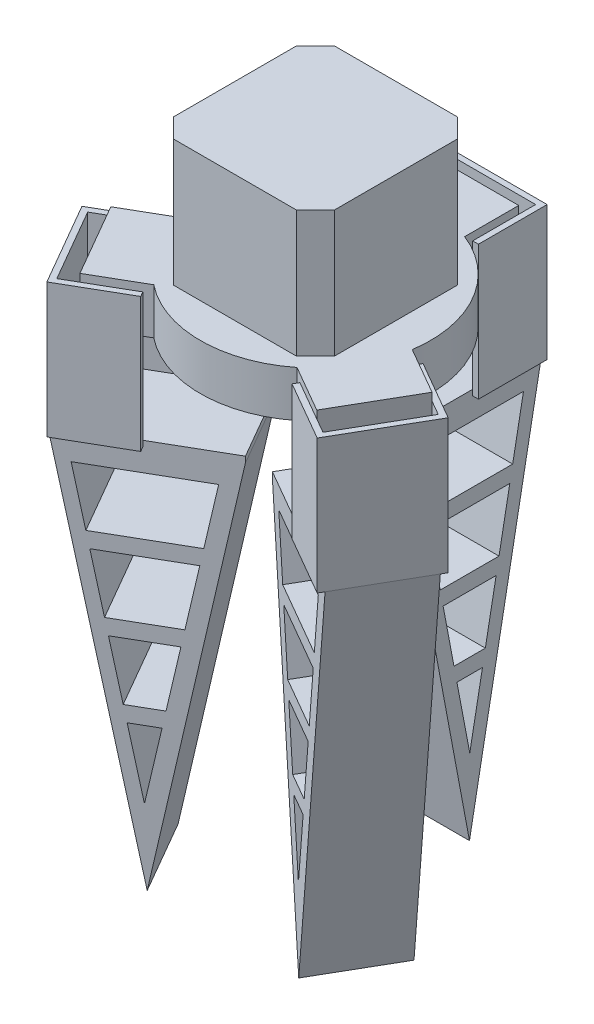
from build123d import *

# Parameters (mm, degrees)
SKETCH_1_W               = 42
SKETCH_1_H               = 42
EXTRUDE_1_DEPTH          = 33
CHAMFER_1_SIZE           = 5
EXTRUDE_2_DEPTH          = 12
EXTRUDE_START            = -10
EXTRUDE_3_DEPTH          = 35
SKETCH_5_W               = 22
SKETCH_5_H               = 36
EXTRUDE_4_DEPTH          = 1.5
EXTRUDE_5_DEPTH          = 22
PATTERN_CIRCULAR_1_COUNT = 3
CUT_EXTRUDE_1_DEPTH      = 65.991772006
CUT_EXTRUDE_2_DEPTH      = 59.741772006
CUT_EXTRUDE_3_DEPTH      = 65.991772006


with BuildPart() as part:
    # Sketch 1 → Extrude 1 (new body)
    with BuildSketch(Plane(origin=(0, 0, 0), x_dir=(1, 0, 0), z_dir=(0, 1, 0))):
        Rectangle(SKETCH_1_W, SKETCH_1_H)
    extrude(amount=EXTRUDE_1_DEPTH)

    # Chamfer 1
    chamfer_1_edges = [part.edges().sort_by_distance(p)[0] for p in [
        (21, 16.5, 21),
        (-21, 16.5, 21),
        (-21, 16.5, -21),
        (21, 16.5, -21),
    ]]
    chamfer(chamfer_1_edges, length=CHAMFER_1_SIZE)

    # Sketch 3 → Extrude 2 (add)
    with BuildSketch(Plane(origin=(0, 0, 0), x_dir=(1, 0, 0), z_dir=(0, 1, 0))):
        with BuildLine():
            Line((-11, 27.910571474), (-11, 42))
            Line((-11, 42), (11, 42))
            Line((11, 42), (11, 27.910571474))
            ThreePointArc((11, 27.910571474), (25.980762114, 15), (29.671263931, -4.429006295))
            Line((29.671263931, -4.429006295), (41.873066959, -11.473720558))
            Line((41.873066959, -11.473720558), (30.873066959, -30.526279442))
            Line((30.873066959, -30.526279442), (18.671263931, -23.481565179))
            ThreePointArc((18.671263931, -23.481565179), (0, -30), (-18.671263931, -23.481565179))
            Line((-18.671263931, -23.481565179), (-30.873066959, -30.526279442))
            Line((-30.873066959, -30.526279442), (-41.873066959, -11.473720558))
            Line((-41.873066959, -11.473720558), (-29.671263931, -4.429006295))
            ThreePointArc((-29.671263931, -4.429006295), (-25.980762114, 15), (-11, 27.910571474))
        make_face()
    extrude(amount=-EXTRUDE_2_DEPTH)

    # Sketch 4 → Extrude 3 (add)
    with BuildSketch(Plane(origin=(0, -12, 0), x_dir=(-1, 0, 0), z_dir=(0, -1, 0)).offset(EXTRUDE_START)):
        Polygon((-11, 30), (-11, 46.410571474), (11, 46.410571474), (11, 30), (12.5, 30), (12.5, 47.910571474), (-12.5, 47.910571474), (-12.5, 30), align=None)
    extrude_3 = extrude(amount=EXTRUDE_3_DEPTH)

    # Sketch 5 → Extrude 4 (add)
    with BuildSketch(Plane(origin=(0, -37, 0), x_dir=(-1, 0, 0), z_dir=(0, -1, 0))):
        with Locations((0, 28.410571474)):
            Rectangle(SKETCH_5_W, SKETCH_5_H)
    extrude_4 = extrude(amount=-EXTRUDE_4_DEPTH)

    # Sketch 6 → Extrude 5 (add)
    with BuildSketch(Plane(origin=(11, 0, 0), x_dir=(0, 0, -1), z_dir=(1, 0, 0))):
        Polygon((10.410571474, -37), (47.910571474, -37), (29.160571474, -137), align=None)
    extrude_5 = extrude(amount=-EXTRUDE_5_DEPTH)

    # Pattern Circular 1: Extrude 3, Extrude 4, Extrude 5 ×3 about axis
    pattern_circular_1_axis = Axis((0, 0, 0), (0, 1, 0))
    for i in range(1, PATTERN_CIRCULAR_1_COUNT):
        add(extrude_3.rotate(pattern_circular_1_axis, i * 360 / PATTERN_CIRCULAR_1_COUNT))
        add(extrude_4.rotate(pattern_circular_1_axis, i * 360 / PATTERN_CIRCULAR_1_COUNT))
        add(extrude_5.rotate(pattern_circular_1_axis, i * 360 / PATTERN_CIRCULAR_1_COUNT))

    # Sketch 7 → Cut-Extrude 1 (cut, through all)
    with BuildSketch(Plane(origin=(5.5, 0, -9.526279442), x_dir=(-0.866025404, 0, -0.5), z_dir=(0.5, 0, -0.866025404))):
        Polygon((-40.245205142, -56), (-17.739434055, -56), (-14.926151928, -41), (-26.07846167, -41), (-43.090866325, -41), align=None)
        Polygon((-39.48636216, -60), (-18.489642622, -60), (-21.302924749, -75), (-36.640700976, -75), align=None)
        Polygon((-35.881857994, -79), (-22.053133316, -79), (-24.866415443, -94), (-33.036196811, -94), align=None)
        Polygon((-28.927933406, -115.655406991), (-25.61662401, -98), (-32.277353829, -98), align=None)
    extrude(amount=-CUT_EXTRUDE_1_DEPTH, mode=Mode.SUBTRACT)

    # Sketch 8 → Cut-Extrude 2 (cut, through all)
    with BuildSketch(Plane(origin=(11, 0, 0), x_dir=(0, 0, -1), z_dir=(1, 0, 0))):
        Polygon((17.91967612, -57.599451379), (40.425447207, -57.599451379), (43.238729334, -42.599451379), (32.086419592, -42.599451379), (15.074014936, -42.599451379), align=None)
        Polygon((18.678519102, -61.599451379), (39.675238639, -61.599451379), (36.861956513, -76.599451379), (21.524180285, -76.599451379), align=None)
        Polygon((22.283023267, -80.599451379), (36.111747945, -80.599451379), (33.298465818, -95.599451379), (25.12868445, -95.599451379), align=None)
        Polygon((29.236947856, -117.25485837), (32.548257251, -99.599451379), (25.887527433, -99.599451379), align=None)
    extrude(amount=-CUT_EXTRUDE_2_DEPTH, mode=Mode.SUBTRACT)

    # Sketch 9 → Cut-Extrude 3 (cut, through all)
    with BuildSketch(Plane(origin=(-5.5, 0, -9.526279442), x_dir=(-0.866025404, 0, 0.5), z_dir=(-0.5, 0, -0.866025404))):
        Polygon((18.364266378, -57.83156369), (40.870037466, -57.83156369), (43.683319592, -42.83156369), (32.531009851, -42.83156369), (15.518605195, -42.83156369), align=None)
        Polygon((19.123109361, -61.83156369), (40.119828898, -61.83156369), (37.306546771, -76.83156369), (21.968770544, -76.83156369), align=None)
        Polygon((22.727613526, -80.83156369), (36.556338204, -80.83156369), (33.743056077, -95.83156369), (25.573274709, -95.83156369), align=None)
        Polygon((29.681538115, -117.486970681), (32.99284751, -99.83156369), (26.332117691, -99.83156369), align=None)
    extrude(amount=-CUT_EXTRUDE_3_DEPTH, mode=Mode.SUBTRACT)


solid = part.part
